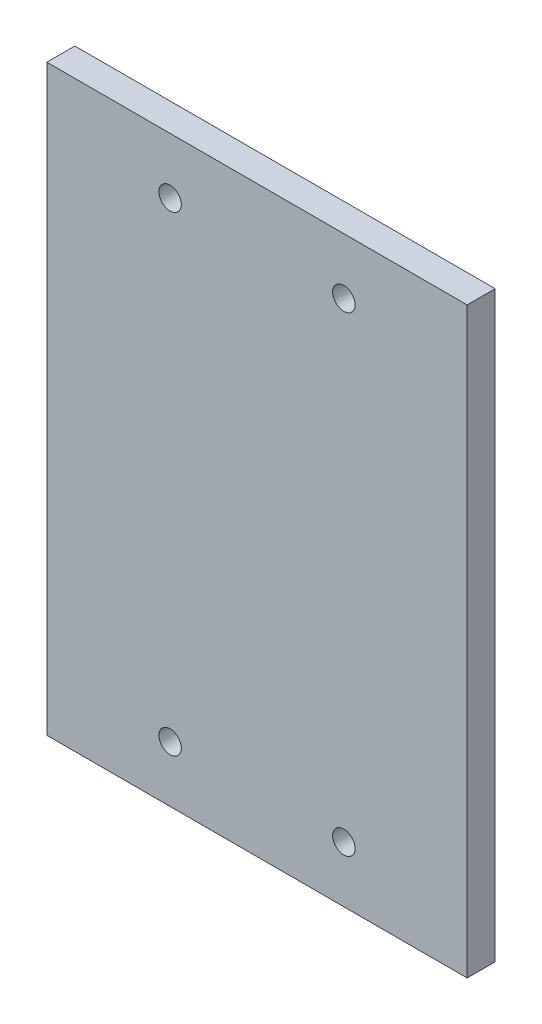
from build123d import *

# Parameters (mm, degrees)
SKETCH1_W           = 75
SKETCH1_H           = 104
SKETCH1_R           = 2
BOSS_EXTRUDE1_DEPTH = 5


with BuildPart() as part:
    # Sketch1 → Boss-Extrude1 (new body)
    with BuildSketch(Plane.XY):
        Rectangle(SKETCH1_W, SKETCH1_H)
        with Locations((15.5, -42)):
            Circle(SKETCH1_R, mode=Mode.SUBTRACT)
        with Locations((-15.5, -42)):
            Circle(SKETCH1_R, mode=Mode.SUBTRACT)
        with Locations((15.5, 42)):
            Circle(SKETCH1_R, mode=Mode.SUBTRACT)
        with Locations((-15.5, 42)):
            Circle(SKETCH1_R, mode=Mode.SUBTRACT)
    extrude(amount=BOSS_EXTRUDE1_DEPTH)


solid = part.part
